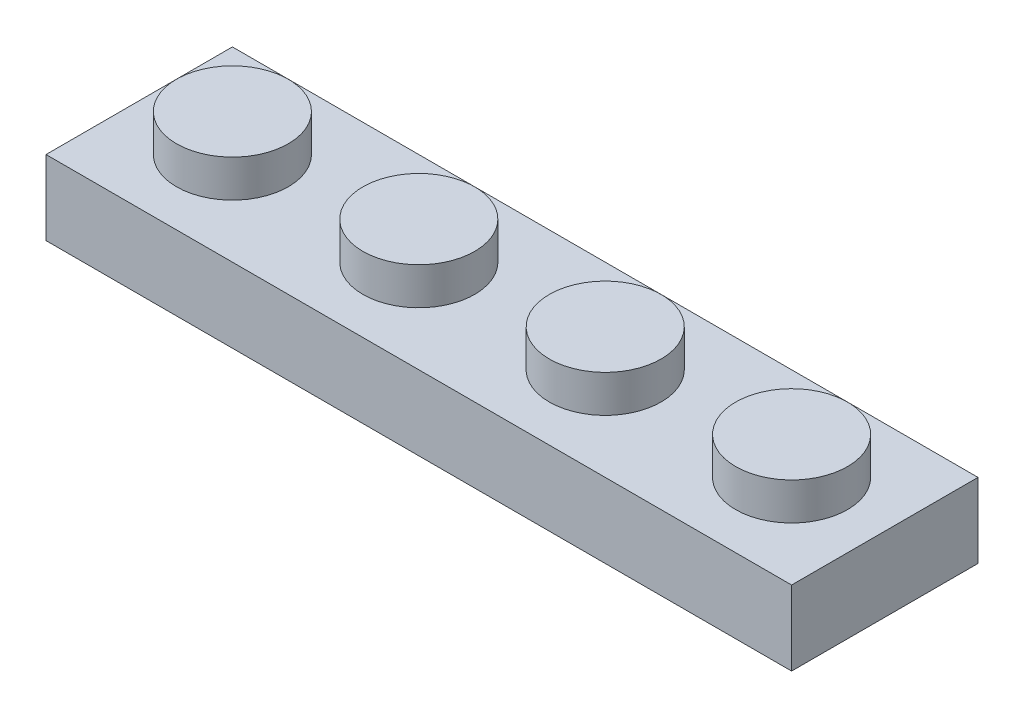
from build123d import *

# Parameters (mm, degrees)
SKETCH1_R             = 1.5
BOSS_EXTRUDE1_DEPTH   = 2
BOSS_EXTRUDE1_2_DEPTH = 2
BOSS_EXTRUDE1_3_DEPTH = 2
BOSS_EXTRUDE1_4_DEPTH = 2
SKETCH1_3_W           = 20
SKETCH1_3_H           = 5
BOSS_EXTRUDE2_DEPTH   = 1
SKETCH1_4_R           = 0.75
CUT_EXTRUDE1_DEPTH    = 1
SKETCH1_5_W           = 20
SKETCH1_5_H           = 5
SKETCH1_5_W_2         = 18
SKETCH1_5_H_2         = 3
SKETCH1_5_R           = 1
BOSS_EXTRUDE3_DEPTH   = 1


with BuildPart() as part:
    # Sketch1 → Boss-Extrude1 (new body)
    with BuildSketch(Plane(origin=(0, 0, 0), x_dir=(1, 0, 0), z_dir=(0, 1, 0))):
        with Locations((-7.5, 0)):
            Circle(SKETCH1_R)
    extrude(amount=BOSS_EXTRUDE1_DEPTH)



with BuildPart() as body_2:
    # Sketch1 → Boss-Extrude1 2 (new body)
    with BuildSketch(Plane(origin=(0, 0, 0), x_dir=(1, 0, 0), z_dir=(0, 1, 0))):
        with Locations((-2.5, 0)):
            Circle(SKETCH1_R)
    extrude(amount=BOSS_EXTRUDE1_2_DEPTH)


with BuildPart() as body_3:
    # Sketch1 → Boss-Extrude1 3 (new body)
    with BuildSketch(Plane(origin=(0, 0, 0), x_dir=(1, 0, 0), z_dir=(0, 1, 0))):
        with Locations((2.5, 0)):
            Circle(SKETCH1_R)
    extrude(amount=BOSS_EXTRUDE1_3_DEPTH)


with BuildPart() as body_4:
    # Sketch1 → Boss-Extrude1 4 (new body)
    with BuildSketch(Plane(origin=(0, 0, 0), x_dir=(1, 0, 0), z_dir=(0, 1, 0))):
        with Locations((7.5, 0)):
            Circle(SKETCH1_R)
    extrude(amount=BOSS_EXTRUDE1_4_DEPTH)


with BuildPart() as part_1:
    add(part.part)

    add(body_2.part)  # Boss-Extrude2 merges body 2

    add(body_3.part)  # Boss-Extrude2 merges body 3

    add(body_4.part)  # Boss-Extrude2 merges body 4
    # Sketch1_3 → Boss-Extrude2 (add)
    with BuildSketch(Plane(origin=(0, 0, 0), x_dir=(1, 0, 0), z_dir=(0, 1, 0))):
        Rectangle(SKETCH1_3_W, SKETCH1_3_H)
    extrude(amount=BOSS_EXTRUDE2_DEPTH)

    # Sketch1_4 → Cut-Extrude1 (cut)
    with BuildSketch(Plane(origin=(0, 0, 0), x_dir=(1, 0, 0), z_dir=(0, 1, 0))):
        with Locations((-7.5, 0)):
            Circle(SKETCH1_4_R)
        with Locations((-2.5, 0)):
            Circle(SKETCH1_4_R)
        with Locations((2.5, 0)):
            Circle(SKETCH1_4_R)
        with Locations((7.5, 0)):
            Circle(SKETCH1_4_R)
    extrude(amount=CUT_EXTRUDE1_DEPTH, mode=Mode.SUBTRACT)

    # Sketch1_5 → Boss-Extrude3 (add)
    # profile 1 of 4: a face of its own
    with BuildSketch(Plane(origin=(0, 0, 0), x_dir=(1, 0, 0), z_dir=(0, 1, 0))):
        Rectangle(SKETCH1_5_W, SKETCH1_5_H)
        Rectangle(SKETCH1_5_W_2, SKETCH1_5_H_2, mode=Mode.SUBTRACT)
    # profile 2 of 4: a face of its own
    with BuildSketch(Plane(origin=(0, 0, 0), x_dir=(1, 0, 0), z_dir=(0, 1, 0))):
        with Locations((5, 0)):
            Circle(SKETCH1_5_R)
    # profile 3 of 4: a face of its own
    with BuildSketch(Plane(origin=(0, 0, 0), x_dir=(1, 0, 0), z_dir=(0, 1, 0))):
        Circle(SKETCH1_5_R)
    # profile 4 of 4: a face of its own
    with BuildSketch(Plane(origin=(0, 0, 0), x_dir=(1, 0, 0), z_dir=(0, 1, 0))):
        with Locations((-5, 0)):
            Circle(SKETCH1_5_R)
    extrude(amount=-BOSS_EXTRUDE3_DEPTH)


solid = part_1.part
